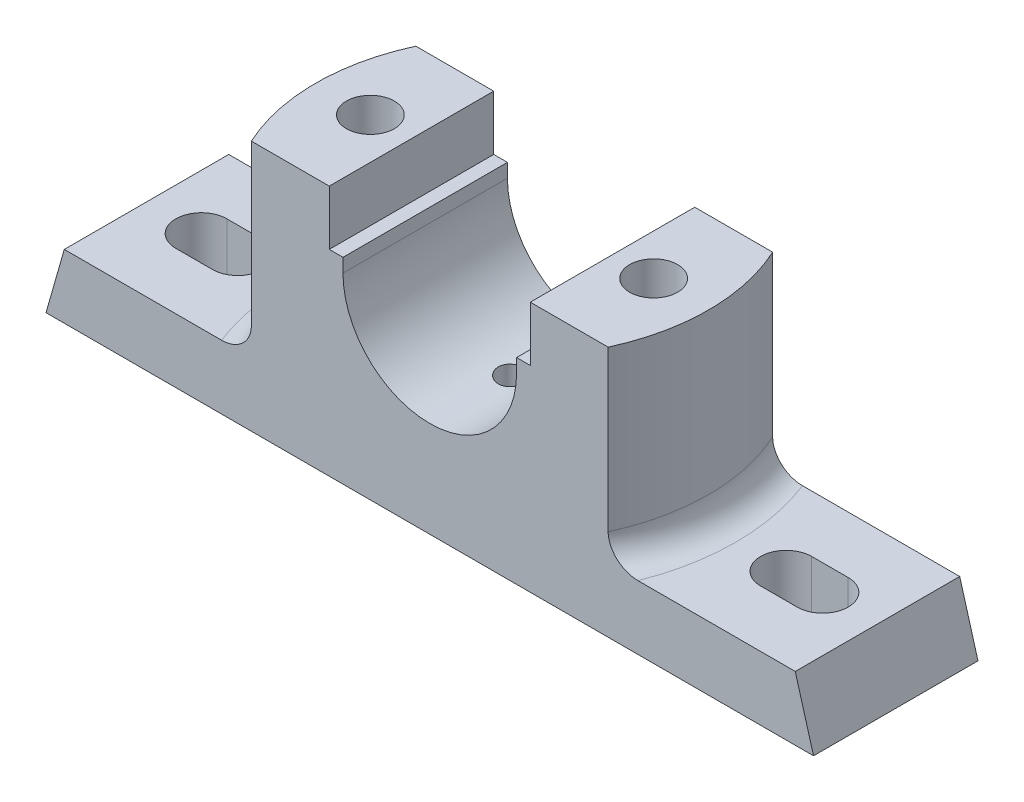
from build123d import *

# Parameters (mm, degrees)
BOSS_EXTRUDE1_DEPTH = 18
BOSS_EXTRUDE2_DEPTH = 41
CUT_EXTRUDE1_DEPTH  = 12
FILLET1_R           = 6
CUT_EXTRUDE2_DEPTH  = 37.0000001
SKETCH7_R           = 5.25
CUT_EXTRUDE3_DEPTH  = 46
SKETCH10_W          = 68
SKETCH10_H          = 20
CUT_EXTRUDE4_DEPTH  = 2
FILLET2_R           = 1
SKETCH11_W          = 20
SKETCH11_H          = 20
CUT_EXTRUDE5_DEPTH  = 9
SKETCH15_R          = 3
CUT_EXTRUDE6_DEPTH  = 10


with BuildPart() as part:
    # Sketch2 → Boss-Extrude1 (new body, symmetric)
    with BuildSketch(Plane.XY):
        Polygon((-84, 0), (84, 0), (80, 14), (-80, 14), align=None)
    extrude(amount=BOSS_EXTRUDE1_DEPTH, both=True)

    # Sketch3 → Boss-Extrude2 (add)
    with BuildSketch(Plane(origin=(0, 14, 0), x_dir=(1, 0, 0), z_dir=(0, 1, 0))):
        with BuildLine():
            Line((-39.05124838, 18), (39.05124838, 18))
            ThreePointArc((39.05124838, 18), (43, 0), (39.05124838, -18))
            Line((39.05124838, -18), (-39.05124838, -18))
            ThreePointArc((-39.05124838, -18), (-43, 0), (-39.05124838, 18))
        make_face()
    extrude(amount=BOSS_EXTRUDE2_DEPTH)

    # Sketch4 → Cut-Extrude1 (cut)
    with BuildSketch(Plane(origin=(0, 14, 0), x_dir=(1, 0, 0), z_dir=(0, 1, 0))):
        with BuildLine():
            Line((60, 5.595094271), (68, 5.595094271))
            ThreePointArc((68, 5.595094271), (73.595094271, 0), (68, -5.595094271))
            Line((68, -5.595094271), (60, -5.595094271))
            ThreePointArc((60, -5.595094271), (54.404905729, 0), (60, 5.595094271))
        make_face()
        with BuildLine():
            Line((-60, 5.595094271), (-68, 5.595094271))
            ThreePointArc((-68, 5.595094271), (-73.595094271, 0), (-68, -5.595094271))
            Line((-68, -5.595094271), (-60, -5.595094271))
            ThreePointArc((-60, -5.595094271), (-54.404905729, 0), (-60, 5.595094271))
        make_face()
    extrude(amount=-CUT_EXTRUDE1_DEPTH, mode=Mode.SUBTRACT)

    # Fillet1
    fillet1_edges = [part.edges().sort_by_distance(p)[0] for p in [
        (43, 14, 0),
        (-43, 14, 0),
    ]]
    fillet(fillet1_edges, radius=FILLET1_R)

    # Sketch5 → Cut-Extrude2 (cut, through all)
    with BuildSketch(Plane.XY.offset(18)):
        with BuildLine():
            Line((22, 55), (22, 43))
            Line((22, 43), (19, 43))
            Line((19, 43), (19, 40))
            ThreePointArc((19, 40), (0, 21), (-19, 40))
            Line((-19, 40), (-19, 43))
            Line((-19, 43), (-22, 43))
            Line((-22, 43), (-22, 55))
            Line((-22, 55), (22, 55))
        make_face()
    extrude(amount=-CUT_EXTRUDE2_DEPTH, mode=Mode.SUBTRACT)

    # Sketch7 → Cut-Extrude3 (cut)
    with BuildSketch(Plane(origin=(0, 55, 0), x_dir=(1, 0, 0), z_dir=(0, 1, 0))):
        with Locations((31, 0)):
            Circle(SKETCH7_R)
        with Locations((-31, 0)):
            Circle(SKETCH7_R)
    extrude(amount=-CUT_EXTRUDE3_DEPTH, mode=Mode.SUBTRACT)

    # Sketch10 → Cut-Extrude4 (cut)
    with BuildSketch(Plane.XZ):
        with Locations((42, 0)):
            Rectangle(SKETCH10_W, SKETCH10_H)
        with Locations((-42, 0)):
            Rectangle(SKETCH10_W, SKETCH10_H)
    extrude(amount=-CUT_EXTRUDE4_DEPTH, mode=Mode.SUBTRACT)

    # Fillet2
    fillet2_edges = [part.edges().sort_by_distance(p)[0] for p in [
        (76, 2, 0),
        (8, 2, 0),
        (-8, 2, 0),
        (-76, 2, 0),
    ]]
    fillet(fillet2_edges, radius=FILLET2_R)

    # Sketch11 → Cut-Extrude5 (cut)
    with BuildSketch(Plane.XZ):
        with Locations((31, 0)):
            Rectangle(SKETCH11_W, SKETCH11_H)
        with Locations((-31, 0)):
            Rectangle(SKETCH11_W, SKETCH11_H)
    extrude(amount=-CUT_EXTRUDE5_DEPTH, mode=Mode.SUBTRACT)

    # Sketch15 → Cut-Extrude6 (cut)
    with BuildSketch(Plane(origin=(0, 25, 0), x_dir=(-1, 0, 0), z_dir=(0, -1, 0))):
        Circle(SKETCH15_R)
    extrude(amount=CUT_EXTRUDE6_DEPTH, mode=Mode.SUBTRACT)


solid = part.part
